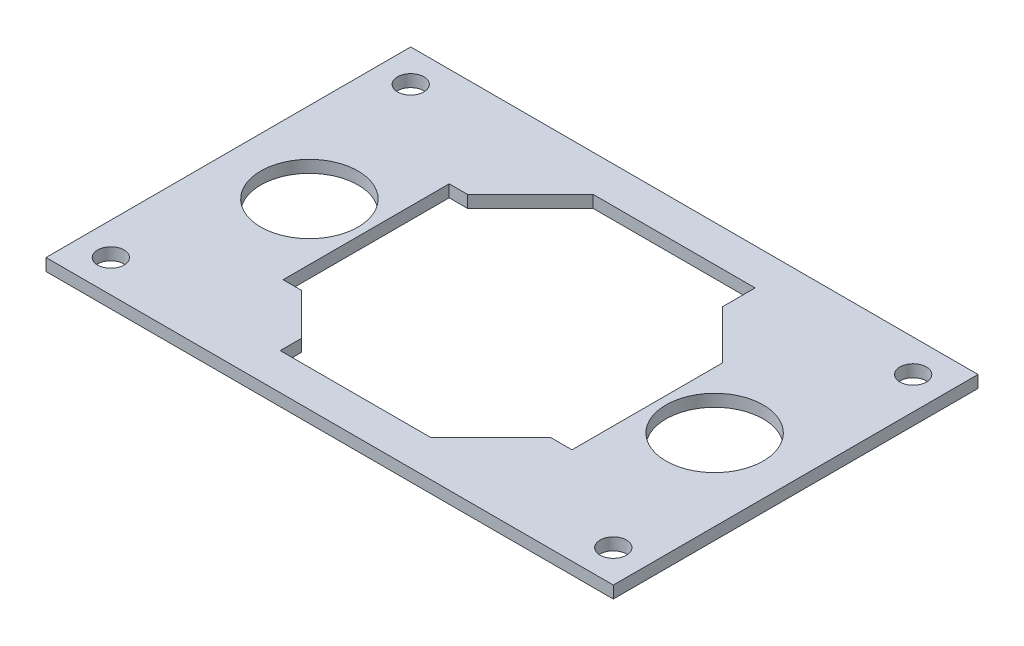
from build123d import *

# Parameters (mm, degrees)
SKETCH2_W           = 70
SKETCH2_H           = 45
BOSS_EXTRUDE1_DEPTH = 1.5
SKETCH3_R           = 1.625
SKETCH3_R_2         = 6
CUT_EXTRUDE1_DEPTH  = 2.5
CUT_EXTRUDE2_DEPTH  = 2.5


with BuildPart() as part:
    # Sketch2 → Boss-Extrude1 (new body)
    with BuildSketch(Plane(origin=(0, 0, 0), x_dir=(1, 0, 0), z_dir=(0, 1, 0))):
        Rectangle(SKETCH2_W, SKETCH2_H)
    extrude(amount=BOSS_EXTRUDE1_DEPTH)

    # Sketch3 → Cut-Extrude1 (cut, through all)
    with BuildSketch(Plane(origin=(0, 1.5, 0), x_dir=(1, 0, 0), z_dir=(0, 1, 0))):
        with Locations((-31, -18.5)):
            Circle(SKETCH3_R)
        with Locations((-31, 18.5)):
            Circle(SKETCH3_R)
        with Locations((31, 18.5)):
            Circle(SKETCH3_R)
        with Locations((31, -18.5)):
            Circle(SKETCH3_R)
        with Locations((-25, 0)):
            Circle(SKETCH3_R_2)
        with Locations((25, 0)):
            Circle(SKETCH3_R_2)
    extrude(amount=-CUT_EXTRUDE1_DEPTH, mode=Mode.SUBTRACT)

    # Sketch4 → Cut-Extrude2 (cut, through all)
    with BuildSketch(Plane(origin=(0, 1.5, 0), x_dir=(1, 0, 0), z_dir=(0, 1, 0))):
        Polygon((-10.6, -18), (-10.6, -15.4), (-15.75, -10.25), (-18, -10.25), (-18, 10.25), (-15.75, 10.25), (-8, 18), (12, 18), (12, 14), (18, 8), (18, -10.6), (15.4, -10.6), (8, -18), align=None)
    extrude(amount=-CUT_EXTRUDE2_DEPTH, mode=Mode.SUBTRACT)


solid = part.part
